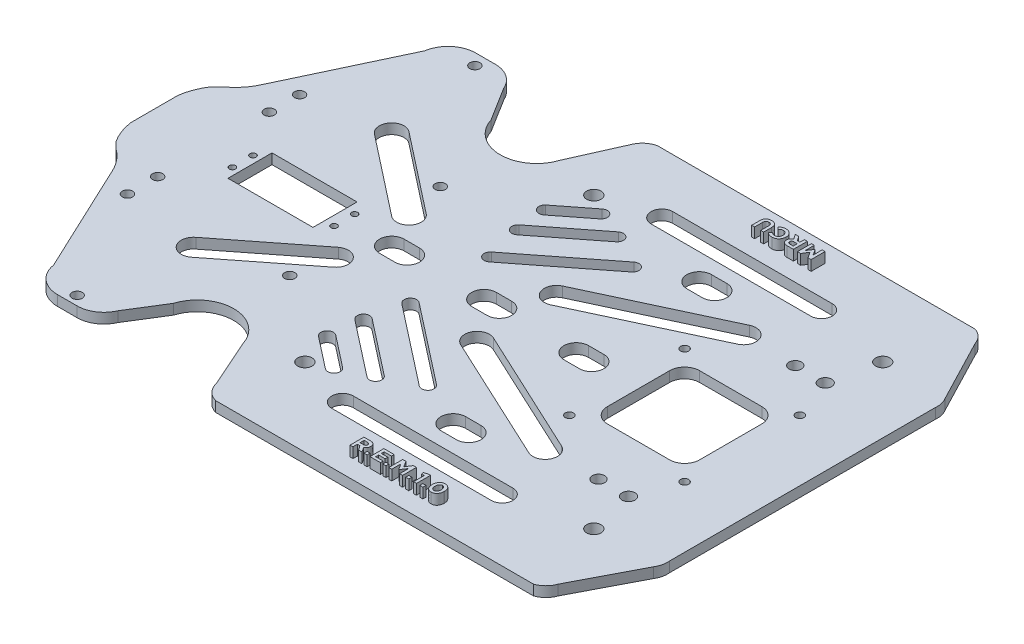
from build123d import *

# Parameters (mm, degrees)
SKETCH1_R           = 3.5
SKETCH1_R_2         = 2.5
SKETCH1_R_3         = 2
SKETCH1_R_4         = 1.5
SKETCH1_W           = 41.5
SKETCH1_H           = 21.5
BOSS_EXTRUDE4_DEPTH = 5
SKETCH2_W           = 1.506426403
SKETCH2_H           = 1.506425042
SKETCH2_W_2         = 1.506426404
BOSS_EXTRUDE5_DEPTH = 5


with BuildPart() as part:
    # Sketch1 → Boss-Extrude4 (new body)
    with BuildSketch(Plane(origin=(0, 0, 0), x_dir=(1, 0, 0), z_dir=(0, 1, 0))):
        with BuildLine():
            Line((-150.651835056, 26.425726461), (-153.297530537, 23.78003098))
            ThreePointArc((-153.297530537, 23.78003098), (-156.293626476, 18.057712499), (-157.845253288, 11.78762686))
            Line((-157.845253288, 11.78762686), (-157.845253288, -10.877537702))
            ThreePointArc((-157.845253288, -10.877537702), (-156.293626476, -17.147623341), (-153.297530537, -22.869941822))
            Line((-153.297530537, -22.869941822), (-150.651835056, -25.515637303))
            ThreePointArc((-150.651835056, -25.515637303), (-145.369806134, -30.45282715), (-141.639142644, -36.646196432))
            Line((-141.639142644, -36.646196432), (-116.473428846, -90.123338253))
            ThreePointArc((-116.473428846, -90.123338253), (-111.887885378, -98.354233742), (-103.050624746, -101.621904773))
            Line((-103.050624746, -101.621904773), (-93.49278288, -101.621904773))
            ThreePointArc((-93.49278288, -101.621904773), (-86.306020072, -99.470384794), (-81.483765332, -93.723693824))
            Line((-81.483765332, -93.723693824), (-71.092160533, -77.045715426))
            ThreePointArc((-71.092160533, -77.045715426), (-54.110025564, -64.559942515), (-37.127890596, -77.045715426))
            Line((-37.127890596, -77.045715426), (-26.687987231, -100.472694386))
            ThreePointArc((-26.687987231, -100.472694386), (-24.195796317, -105.133358769), (-19.658180017, -107.843127459))
            Line((-19.658180017, -107.843127459), (135.416108394, -107.843127459))
            ThreePointArc((135.416108394, -107.843127459), (139.142837684, -105.522737893), (141.474846039, -101.803268042))
            Line((141.474846039, -101.803268042), (157.346216018, -71.285102391))
            ThreePointArc((157.346216018, -71.285102391), (158.635275777, -68.269644616), (158.852211618, -64.997397759))
            Line((158.852211618, -64.997397759), (158.852211618, 64.840104165))
            ThreePointArc((158.852211618, 64.840104165), (158.635275777, 68.112351022), (157.346216018, 71.127808797))
            Line((157.346216018, 71.127808797), (141.474846039, 101.645974448))
            ThreePointArc((141.474846039, 101.645974448), (139.142837684, 105.365444299), (135.416108394, 107.685833865))
            Line((135.416108394, 107.685833865), (-19.658180017, 107.685833865))
            ThreePointArc((-19.658180017, 107.685833865), (-23.974543285, 105.428178597), (-26.687987231, 101.382783544))
            Line((-26.687987231, 101.382783544), (-37.127890596, 77.955804584))
            ThreePointArc((-37.127890596, 77.955804584), (-54.110025564, 65.470031673), (-71.092160533, 77.955804584))
            Line((-71.092160533, 77.955804584), (-81.483765332, 94.633782983))
            ThreePointArc((-81.483765332, 94.633782983), (-86.306020072, 100.380473953), (-93.49278288, 102.531993931))
            Line((-93.49278288, 102.531993931), (-103.050624746, 102.531993931))
            ThreePointArc((-103.050624746, 102.531993931), (-111.887885378, 99.2643229), (-116.473428846, 91.033427412))
            Line((-116.473428846, 91.033427412), (-141.639142644, 37.55628559))
            ThreePointArc((-141.639142644, 37.55628559), (-145.369806134, 31.362916309), (-150.651835056, 26.425726461))
        make_face()
        with Locations((126.785350398, 71.251763002)):
            Circle(SKETCH1_R, mode=Mode.SUBTRACT)
        with Locations((126.785350398, -69.748236998)):
            Circle(SKETCH1_R, mode=Mode.SUBTRACT)
        with Locations((-14.214649602, -69.748236998)):
            Circle(SKETCH1_R, mode=Mode.SUBTRACT)
        with Locations((-14.214649602, 71.251763002)):
            Circle(SKETCH1_R, mode=Mode.SUBTRACT)
        with Locations((-55.317055283, 37.432698705)):
            Circle(SKETCH1_R_2, mode=Mode.SUBTRACT)
        with Locations((-97.94691387, -97.121904773)):
            Circle(SKETCH1_R_2, mode=Mode.SUBTRACT)
        with Locations((-54.44373788, -36.910189328)):
            Circle(SKETCH1_R_2, mode=Mode.SUBTRACT)
        with Locations((-128.469873776, -27.328127459)):
            Circle(SKETCH1_R_2, mode=Mode.SUBTRACT)
        with Locations((129.066717469, 28.522168049)):
            Circle(SKETCH1_R_3, mode=Mode.SUBTRACT)
        with Locations((72.816717469, 28.522168049)):
            Circle(SKETCH1_R_3, mode=Mode.SUBTRACT)
        with Locations((72.816717469, -27.727831951)):
            Circle(SKETCH1_R_3, mode=Mode.SUBTRACT)
        with Locations((129.066717469, -27.727831951)):
            Circle(SKETCH1_R_3, mode=Mode.SUBTRACT)
        with Locations((-128.469873776, -42.068127459)):
            Circle(SKETCH1_R_2, mode=Mode.SUBTRACT)
        with Locations((-128.469873776, 41.911872541)):
            Circle(SKETCH1_R_2, mode=Mode.SUBTRACT)
        with Locations((-128.469873776, 27.171872541)):
            Circle(SKETCH1_R_2, mode=Mode.SUBTRACT)
        with Locations((-114.159440978, -5.164282294)):
            Circle(SKETCH1_R_4, mode=Mode.SUBTRACT)
        with Locations((-114.159440978, 4.885717706)):
            Circle(SKETCH1_R_4, mode=Mode.SUBTRACT)
        with Locations((-64.559440978, -5.164282294)):
            Circle(SKETCH1_R_4, mode=Mode.SUBTRACT)
        with Locations((-64.559440978, 4.885717706)):
            Circle(SKETCH1_R_4, mode=Mode.SUBTRACT)
        with Locations((-97.94691387, 96.965649855)):
            Circle(SKETCH1_R_2, mode=Mode.SUBTRACT)
        with BuildLine():
            Line((89.809281898, 83.569651302), (11.952031041, 83.569651302))
            ThreePointArc((11.952031041, 83.569651302), (6.702031041, 78.319651302), (11.952031041, 73.069651302))
            Line((11.952031041, 73.069651302), (89.809281898, 73.069651302))
            ThreePointArc((89.809281898, 73.069651302), (95.059281898, 78.319651302), (89.809281898, 83.569651302))
        make_face(mode=Mode.SUBTRACT)
        with BuildLine():
            Line((-6.436015983, 67.378434735), (-21.802225678, 55.373035966))
            ThreePointArc((-21.802225678, 55.373035966), (-22.672033007, 52.052777973), (-19.856796521, 50.089331651))
            ThreePointArc((-19.856796521, 50.089331651), (-18.936348022, 50.234025265), (-18.104688203, 50.654148611))
            Line((-18.104688203, 50.654148611), (-2.738478508, 62.65954738))
            ThreePointArc((-2.738478508, 62.65954738), (-2.129164012, 66.945049932), (-6.436015983, 67.378434735))
        make_face(mode=Mode.SUBTRACT)
        with BuildLine():
            Line((7.280972286, 61.712167773), (-19.905398714, 40.471846874))
            ThreePointArc((-19.905398714, 40.471846874), (-20.894970014, 37.13111015), (-18.058414288, 35.107814614))
            ThreePointArc((-18.058414288, 35.107814614), (-17.081709824, 35.271258887), (-16.211429862, 35.743782353))
            Line((-16.211429862, 35.743782353), (10.974941138, 56.984103252))
            ThreePointArc((10.974941138, 56.984103252), (11.491988973, 61.195119938), (7.280972286, 61.712167773))
        make_face(mode=Mode.SUBTRACT)
        with BuildLine():
            Line((23.811213387, 52.736443338), (-15.195318916, 22.26120031))
            ThreePointArc((-15.195318916, 22.26120031), (-16.184890217, 18.920463586), (-13.34833449, 16.897168049))
            ThreePointArc((-13.34833449, 16.897168049), (-12.371630027, 17.060612322), (-11.501350064, 17.533135788))
            Line((-11.501350064, 17.533135788), (27.505182239, 48.008378817))
            ThreePointArc((27.505182239, 48.008378817), (28.022230074, 52.219395504), (23.811213387, 52.736443338))
        make_face(mode=Mode.SUBTRACT)
        with BuildLine():
            Line((78.802429375, 54.275484778), (16.546859215, 25.24523565))
            ThreePointArc((16.546859215, 25.24523565), (13.644722064, 17.271679357), (21.618278356, 14.369542206))
            Line((21.618278356, 14.369542206), (83.873848516, 43.399791334))
            ThreePointArc((83.873848516, 43.399791334), (87.195914988, 50.13627574), (81.338138945, 54.837638056))
            ThreePointArc((81.338138945, 54.837638056), (80.039501262, 54.695414099), (78.802429375, 54.275484778))
        make_face(mode=Mode.SUBTRACT)
        with BuildLine():
            Line((48.066717469, 54.397168049), (55.566717469, 54.397168049))
            ThreePointArc((55.566717469, 54.397168049), (61.566717469, 60.397168049), (55.566717469, 66.397168049))
            Line((55.566717469, 66.397168049), (48.066717469, 66.397168049))
            ThreePointArc((48.066717469, 66.397168049), (42.066717469, 60.397168049), (48.066717469, 54.397168049))
        make_face(mode=Mode.SUBTRACT)
        with BuildLine():
            Line((-86.060715194, -53.061693245), (-47.099872951, -22.528059794))
            ThreePointArc((-47.099872951, -22.528059794), (-46.177380086, -14.181028105), (-54.50374552, -13.08760698))
            Line((-54.50374552, -13.08760698), (-93.464587763, -43.621240431))
            ThreePointArc((-93.464587763, -43.621240431), (-95.550522316, -50.317795247), (-89.859440978, -54.417376028))
            ThreePointArc((-89.859440978, -54.417376028), (-87.84274855, -54.068300877), (-86.060715194, -53.061693245))
        make_face(mode=Mode.SUBTRACT)
        with BuildLine():
            Line((48.066717469, -5.602831951), (55.566717469, -5.602831951))
            ThreePointArc((55.566717469, -5.602831951), (61.566717469, 0.397168049), (55.566717469, 6.397168049))
            Line((55.566717469, 6.397168049), (48.066717469, 6.397168049))
            ThreePointArc((48.066717469, 6.397168049), (42.066717469, 0.397168049), (48.066717469, -5.602831951))
        make_face(mode=Mode.SUBTRACT)
        with BuildLine():
            Line((3.066717469, -5.602831951), (10.566717469, -5.602831951))
            ThreePointArc((10.566717469, -5.602831951), (16.566717469, 0.397168049), (10.566717469, 6.397168049))
            Line((10.566717469, 6.397168049), (3.066717469, 6.397168049))
            ThreePointArc((3.066717469, 6.397168049), (-2.933282531, 0.397168049), (3.066717469, -5.602831951))
        make_face(mode=Mode.SUBTRACT)
        with BuildLine():
            Line((-41.933282531, -5.602831951), (-34.433282531, -5.602831951))
            ThreePointArc((-34.433282531, -5.602831951), (-28.433282531, 0.397168049), (-34.433282531, 6.397168049))
            Line((-34.433282531, 6.397168049), (-41.933282531, 6.397168049))
            ThreePointArc((-41.933282531, 6.397168049), (-47.933282531, 0.397168049), (-41.933282531, -5.602831951))
        make_face(mode=Mode.SUBTRACT)
        with BuildLine():
            Line((-19.905398714, -39.677510776), (7.280972286, -60.917831675))
            ThreePointArc((7.280972286, -60.917831675), (8.151252249, -61.390355141), (9.127956712, -61.553799414))
            ThreePointArc((9.127956712, -61.553799414), (11.964512439, -59.530503878), (10.974941138, -56.189767154))
            Line((10.974941138, -56.189767154), (-16.211429862, -34.949446255))
            ThreePointArc((-16.211429862, -34.949446255), (-20.422446548, -35.46649409), (-19.905398714, -39.677510776))
        make_face(mode=Mode.SUBTRACT)
        with BuildLine():
            Line((-15.195318916, -21.466864212), (23.811213387, -51.94210724))
            ThreePointArc((23.811213387, -51.94210724), (24.68149335, -52.414630706), (25.658197813, -52.57807498))
            ThreePointArc((25.658197813, -52.57807498), (28.49475354, -50.554779443), (27.505182239, -47.214042719))
            Line((27.505182239, -47.214042719), (-11.501350064, -16.73879969))
            ThreePointArc((-11.501350064, -16.73879969), (-15.712366751, -17.255847525), (-15.195318916, -21.466864212))
        make_face(mode=Mode.SUBTRACT)
        with BuildLine():
            Line((48.066717469, -65.602831951), (55.566717469, -65.602831951))
            ThreePointArc((55.566717469, -65.602831951), (61.566717469, -59.602831951), (55.566717469, -53.602831951))
            Line((55.566717469, -53.602831951), (48.066717469, -53.602831951))
            ThreePointArc((48.066717469, -53.602831951), (42.066717469, -59.602831951), (48.066717469, -65.602831951))
        make_face(mode=Mode.SUBTRACT)
        with BuildLine():
            Line((11.952031041, -82.775315204), (89.809281898, -82.775315204))
            ThreePointArc((89.809281898, -82.775315204), (95.059281898, -77.525315204), (89.809281898, -72.275315204))
            Line((89.809281898, -72.275315204), (11.952031041, -72.275315204))
            ThreePointArc((11.952031041, -72.275315204), (6.702031041, -77.525315204), (11.952031041, -82.775315204))
        make_face(mode=Mode.SUBTRACT)
        with BuildLine():
            Line((116.134000275, 22.897168049), (85.749434663, 22.897168049))
            ThreePointArc((85.749434663, 22.897168049), (80.58209828, 20.756787238), (78.441717469, 15.589450855))
            Line((78.441717469, 15.589450855), (78.441717469, -14.795114757))
            ThreePointArc((78.441717469, -14.795114757), (80.58209828, -19.96245114), (85.749434663, -22.102831951))
            Line((85.749434663, -22.102831951), (116.134000275, -22.102831951))
            ThreePointArc((116.134000275, -22.102831951), (121.301336658, -19.96245114), (123.441717469, -14.795114757))
            Line((123.441717469, -14.795114757), (123.441717469, 15.589450855))
            ThreePointArc((123.441717469, 15.589450855), (121.301336658, 20.756787238), (116.134000275, 22.897168049))
        make_face(mode=Mode.SUBTRACT)
        with BuildLine():
            Line((16.546859215, -24.450899552), (78.802429375, -53.48114868))
            ThreePointArc((78.802429375, -53.48114868), (86.775985667, -50.579011528), (83.873848516, -42.605455236))
            Line((83.873848516, -42.605455236), (21.618278356, -13.575206108))
            ThreePointArc((21.618278356, -13.575206108), (20.381206469, -13.155276787), (19.082568786, -13.01305283))
            ThreePointArc((19.082568786, -13.01305283), (13.224792743, -17.714415146), (16.546859215, -24.450899552))
        make_face(mode=Mode.SUBTRACT)
        with BuildLine():
            Line((-86.060715194, 52.905438327), (-47.099872951, 22.371804877))
            ThreePointArc((-47.099872951, 22.371804877), (-46.177380086, 14.024773187), (-54.50374552, 12.931352063))
            Line((-54.50374552, 12.931352063), (-93.464587763, 43.464985514))
            ThreePointArc((-93.464587763, 43.464985514), (-95.550522316, 50.16154033), (-89.859440978, 54.26112111))
            ThreePointArc((-89.859440978, 54.26112111), (-87.84274855, 53.912045959), (-86.060715194, 52.905438327))
        make_face(mode=Mode.SUBTRACT)
        with BuildLine():
            Line((-18.104688203, -50.810403528), (-2.738478508, -62.815802297))
            ThreePointArc((-2.738478508, -62.815802297), (-2.129164012, -67.101304849), (-6.436015983, -67.534689652))
            Line((-6.436015983, -67.534689652), (-21.802225678, -55.529290883))
            ThreePointArc((-21.802225678, -55.529290883), (-22.672033007, -52.20903289), (-19.856796521, -50.245586569))
            ThreePointArc((-19.856796521, -50.245586569), (-18.936348022, -50.390280182), (-18.104688203, -50.810403528))
        make_face(mode=Mode.SUBTRACT)
        with Locations((-89.859440978, -0.139282294)):
            Rectangle(SKETCH1_W, SKETCH1_H, mode=Mode.SUBTRACT)
        with BuildLine():
            ThreePointArc((121.566717469, 45.247168049), (124.716717469, 48.397168049), (121.566717469, 51.547168049))
            ThreePointArc((121.566717469, 51.547168049), (118.416717469, 48.397168049), (121.566717469, 45.247168049))
        make_face(mode=Mode.SUBTRACT)
        with BuildLine():
            ThreePointArc((106.941717469, 45.397168049), (109.941717469, 48.397168049), (106.941717469, 51.397168049))
            ThreePointArc((106.941717469, 51.397168049), (103.941717469, 48.397168049), (106.941717469, 45.397168049))
        make_face(mode=Mode.SUBTRACT)
        with BuildLine():
            ThreePointArc((106.941717469, -50.602831951), (109.941717469, -47.602831951), (106.941717469, -44.602831951))
            ThreePointArc((106.941717469, -44.602831951), (103.941717469, -47.602831951), (106.941717469, -50.602831951))
        make_face(mode=Mode.SUBTRACT)
        with BuildLine():
            ThreePointArc((121.566717469, -44.452831951), (118.416717469, -47.602831951), (121.566717469, -50.752831951))
            ThreePointArc((121.566717469, -50.752831951), (124.716717469, -47.602831951), (121.566717469, -44.452831951))
        make_face(mode=Mode.SUBTRACT)
    extrude(amount=BOSS_EXTRUDE4_DEPTH)

    # Sketch2 → Boss-Extrude5 (add)
    with BuildSketch(Plane(origin=(0, 5, 0), x_dir=(1, 0, 0), z_dir=(0, 1, 0))):
        with BuildLine():
            Line((36.93226285, -98.837549469), (38.349419621, -98.837549469))
            Line((38.349419621, -98.837549469), (38.349419621, -96.686741963))
            Line((38.349419621, -96.686741963), (39.576502472, -96.686741963))
            Line((39.576502472, -96.686741963), (41.097679559, -98.837549469))
            Line((41.097679559, -98.837549469), (42.747557695, -98.837549469))
            Line((42.747557695, -98.837549469), (41.182439124, -96.436068869))
            add(Edge.make_bspline(
                [(41.182439124, -96.436068869), (41.232495375, -96.415759477), (41.331901229, -96.375427403), (41.474000985, -96.301982888), (41.609887155, -96.221621628), (41.737392019, -96.130727901), (41.855371764, -96.02940522), (41.968290704, -95.922342324), (42.071493, -95.804062865), (42.16763074, -95.677708417), (42.2552616, -95.54173216), (42.329839018, -95.395088162), (42.394511693, -95.239423439), (42.447376928, -95.074204287), (42.489191442, -94.898889314), (42.519806985, -94.71388545), (42.537490295, -94.518990612), (42.541597203, -94.386188466), (42.54369749, -94.318272983)],
                knots=[0, 0, 0, 0, 0.000161982, 0.000321677, 0.000479319, 0.000635304, 0.000790683, 0.00094556, 0.001101707, 0.001261, 0.001421576, 0.001586267, 0.001753863, 0.001926777, 0.002106083, 0.002294118, 0.002488846, 0.002692664, 0.002692664, 0.002692664, 0.002692664], degree=3))
            Line((42.54369749, -94.318272983), (42.545090966, -94.298053281))
            add(Edge.make_bspline(
                [(42.545090966, -94.298053281), (42.542503237, -94.217781145), (42.537456432, -94.061227784), (42.511176344, -93.833230559), (42.467552585, -93.618787705), (42.409769876, -93.41649459), (42.332984582, -93.2275577), (42.238330846, -93.052617737), (42.130622181, -92.88825266), (42.043339274, -92.791742001), (41.99971067, -92.74350088)],
                knots=[0, 0, 0, 0, 0.000240874, 0.000469772, 0.000687518, 0.000896744, 0.001100075, 0.001297896, 0.001492874, 0.001687738, 0.001687738, 0.001687738, 0.001687738], degree=3))
            add(Edge.make_bspline(
                [(41.99971067, -92.74350088), (41.945832837, -92.689741667), (41.836879962, -92.581028666), (41.643703577, -92.446853047), (41.430781132, -92.330129995), (41.194186774, -92.235350066), (40.935109055, -92.161889992), (40.653448337, -92.110125592), (40.349982268, -92.075790004), (40.140025549, -92.070916295), (40.03159425, -92.068399287)],
                knots=[0, 0, 0, 0, 0.00022794, 0.000460945, 0.000702509, 0.00095531, 0.001223736, 0.001509064, 0.00181359, 0.00213883, 0.00213883, 0.00213883, 0.00213883], degree=3))
            Line((40.03159425, -92.068399287), (36.93226285, -92.067733198))
            Line((36.93226285, -92.067733198), (36.93226285, -98.837549469))
        make_face()
        with BuildLine():
            Line((38.349419621, -95.375528859), (38.349419621, -93.388586212))
            Line((38.349419621, -93.388586212), (39.90102025, -93.388586212))
            add(Edge.make_bspline(
                [(39.90102025, -93.388586212), (39.947351753, -93.389797843), (40.037998232, -93.39216837), (40.170235041, -93.402765258), (40.295218415, -93.422259631), (40.411755282, -93.449974111), (40.520697691, -93.484830285), (40.620962277, -93.528109733), (40.714160049, -93.578577766), (40.799044614, -93.636738217), (40.875368997, -93.703143775), (40.942543438, -93.776644392), (40.998655142, -93.858650729), (41.045171969, -93.947509497), (41.081974, -94.044312621), (41.105645619, -94.149605066), (41.123784414, -94.261402748), (41.125607486, -94.33865021), (41.126542081, -94.378251017)],
                knots=[0, 0, 0, 0, 0.00013903, 0.000272008, 0.000397675, 0.000518117, 0.000631039, 0.00074038, 0.000845244, 0.000948547, 0.001048402, 0.00114814, 0.001246414, 0.001345615, 0.001448464, 0.001556048, 0.001668883, 0.001787576, 0.001787576, 0.001787576, 0.001787576], degree=3))
            Line((41.126542081, -94.378251017), (41.127934195, -94.396904251))
            add(Edge.make_bspline(
                [(41.127934195, -94.396904251), (41.126247912, -94.433054739), (41.12293983, -94.503973327), (41.10730277, -94.606933424), (41.084152772, -94.705105517), (41.048762926, -94.796354176), (41.00578855, -94.883331503), (40.949910347, -94.962401867), (40.888028968, -95.03867147), (40.814141188, -95.106401341), (40.734062586, -95.1705669), (40.642155284, -95.222184612), (40.544324755, -95.269341796), (40.437343757, -95.306137219), (40.323012178, -95.337788737), (40.199452692, -95.357294643), (40.068208854, -95.37213903), (39.977707149, -95.374398326), (39.931165914, -95.375560188)],
                knots=[0, 0, 0, 0, 0.000108501, 0.000212853, 0.000311975, 0.000410418, 0.00050586, 0.000602194, 0.000700241, 0.000799901, 0.000902296, 0.001007317, 0.001115261, 0.00122776, 0.001346182, 0.001470698, 0.001602553, 0.001742148, 0.001742148, 0.001742148, 0.001742148], degree=3))
            Line((39.931165914, -95.375560188), (38.349419621, -95.375528859))
        make_face(mode=Mode.SUBTRACT)
        with Locations((44.469968088, -98.084335586)):
            Rectangle(SKETCH2_W, SKETCH2_H)
        Polygon((46.662652745, -98.834032407), (51.74349319, -98.834032407), (51.74349319, -97.51317803), (48.079809517, -97.51317803), (48.079809517, -96.066675175), (51.261429548, -96.066675175), (51.261429548, -94.745820798), (48.079809517, -94.745820798), (48.079809517, -93.388587575), (51.695286826, -93.388587575), (51.695286826, -92.067733198), (46.662652745, -92.067733198), align=None)
        with Locations((53.664740192, -98.084335586)):
            Rectangle(SKETCH2_W_2, SKETCH2_H)
        Polygon((55.857424849, -98.837549469), (57.27458162, -98.837549469), (57.27458162, -94.44433283), (59.170301316, -97.308632665), (59.209187874, -97.308632665), (61.124331779, -94.415302764), (61.124331779, -98.837549469), (62.54148855, -98.837549469), (62.54148855, -92.064216135), (60.997969536, -92.064216135), (59.209187874, -94.928167261), (57.420406212, -92.064216135), (55.857424849, -92.064216135), align=None)
        with Locations((64.823444201, -98.084335586)):
            Rectangle(SKETCH2_W, SKETCH2_H)
        Polygon((67.908825178, -98.837549469), (69.325981949, -98.837549469), (69.325981949, -91.974946503), (68.347048135, -91.974946503), (66.424069163, -92.559184752), (66.732589893, -93.785655999), (67.908825178, -93.493639036), align=None)
        with Locations((71.69720587, -98.084335586)):
            Rectangle(SKETCH2_W_2, SKETCH2_H)
        with BuildLine():
            add(Edge.make_bspline(
                [(76.552539558, -98.923302039), (76.664395208, -98.918547638), (76.883724755, -98.909225082), (77.202145933, -98.854101454), (77.503473369, -98.774553925), (77.784730456, -98.661893535), (78.047930418, -98.522192428), (78.290928278, -98.351535691), (78.515412117, -98.152490064), (78.718016633, -97.924888376), (78.898947463, -97.674585124), (79.058269442, -97.40688599), (79.192969897, -97.121424241), (79.302681056, -96.819599732), (79.389455575, -96.501419513), (79.451715618, -96.166483495), (79.491400556, -95.814935788), (79.497975912, -95.574662862), (79.501325167, -95.452276278)],
                knots=[0, 0, 0, 0, 0.000335555, 0.000657964, 0.000967229, 0.001268981, 0.001564769, 0.001859242, 0.002157633, 0.00246286, 0.002771435, 0.003082893, 0.003396111, 0.003716915, 0.004045141, 0.004384365, 0.004738027, 0.00510519, 0.00510519, 0.00510519, 0.00510519], degree=3))
            Line((79.501325167, -95.452276278), (79.502718643, -95.431628862))
            add(Edge.make_bspline(
                [(79.502718643, -95.431628862), (79.498770665, -95.309624848), (79.491023842, -95.070225471), (79.451884434, -94.719420375), (79.388742461, -94.385338133), (79.305510745, -94.066963449), (79.1917957, -93.767448324), (79.05896229, -93.48318106), (78.900097524, -93.216735411), (78.71925676, -92.969000607), (78.518719866, -92.742224339), (78.294687849, -92.545950631), (78.053350496, -92.377511301), (77.793885924, -92.236247912), (77.513959944, -92.128166294), (77.216818781, -92.047084061), (76.900792162, -91.994464121), (76.683491224, -91.98432437), (76.572165365, -91.979129655)],
                knots=[0, 0, 0, 0, 0.000366105, 0.000718381, 0.001057605, 0.001385466, 0.001704137, 0.002017355, 0.002325703, 0.00263315, 0.002936408, 0.003231906, 0.003524437, 0.003817767, 0.004115901, 0.004422473, 0.004740527, 0.00507464, 0.00507464, 0.00507464, 0.00507464], degree=3))
            add(Edge.make_bspline(
                [(76.572165365, -91.979129655), (76.45988236, -91.984159811), (76.240602931, -91.993983288), (75.92257871, -92.048866643), (75.623077498, -92.129080696), (75.34179369, -92.239534211), (75.080083095, -92.381315208), (74.836621741, -92.551508977), (74.612106432, -92.750637205), (74.409744741, -92.978720254), (74.226983706, -93.228057583), (74.068209768, -93.496662579), (73.931853286, -93.78164003), (73.820336852, -94.08327588), (73.734287678, -94.40236784), (73.670058895, -94.736993057), (73.630591203, -95.089161883), (73.624038504, -95.329429251), (73.620688155, -95.452276278)],
                knots=[0, 0, 0, 0, 0.000336896, 0.00065793, 0.000965848, 0.00126579, 0.001562238, 0.001856711, 0.002155102, 0.00246033, 0.002769726, 0.003081184, 0.003395001, 0.003716287, 0.004044512, 0.004385367, 0.004737643, 0.0051062, 0.0051062, 0.0051062, 0.0051062], degree=3))
            Line((73.620688155, -95.452276278), (73.622081631, -95.470221196))
            add(Edge.make_bspline(
                [(73.622081631, -95.470221196), (73.624982102, -95.592659544), (73.63066324, -95.832478875), (73.668652506, -96.183771774), (73.731257188, -96.51814016), (73.81761749, -96.835365071), (73.926933066, -97.135964285), (74.05874552, -97.420295519), (74.217884707, -97.685988184), (74.397111822, -97.934112307), (74.596358502, -98.161324786), (74.82039871, -98.357166838), (75.061688919, -98.525624656), (75.321485458, -98.667246201), (75.602523844, -98.774928493), (75.901453672, -98.856264198), (76.219850811, -98.908654886), (76.438991861, -98.918820775), (76.551242795, -98.924028063)],
                knots=[0, 0, 0, 0, 0.000367295, 0.000719419, 0.001058643, 0.001386869, 0.001704574, 0.002017198, 0.002325546, 0.002632172, 0.002934502, 0.00323, 0.00352253, 0.003815861, 0.004115294, 0.004423212, 0.004744019, 0.005080915, 0.005080915, 0.005080915, 0.005080915], degree=3))
            Line((76.551242795, -98.924028063), (76.552539558, -98.923302039))
        make_face()
        with BuildLine():
            add(Edge.make_bspline(
                [(76.572451416, -97.602447662), (76.515040198, -97.599308317), (76.402775174, -97.593169471), (76.238900644, -97.562251991), (76.085208084, -97.511395499), (75.93925005, -97.444336986), (75.804088664, -97.356875341), (75.677194976, -97.253021349), (75.561022806, -97.13004738), (75.454432819, -96.990989379), (75.358083707, -96.837404551), (75.274995706, -96.671245545), (75.203402789, -96.494545811), (75.144966075, -96.306949303), (75.099225675, -96.108740314), (75.065832778, -95.899510737), (75.044743511, -95.679591376), (75.041097453, -95.529039605), (75.039238402, -95.452276278)],
                knots=[0, 0, 0, 0, 0.000172363, 0.000337049, 0.000498489, 0.000656992, 0.000817568, 0.000980089, 0.001147806, 0.001323849, 0.001504969, 0.001690859, 0.00188046, 0.002076334, 0.002279679, 0.002490189, 0.002711564, 0.002941865, 0.002941865, 0.002941865, 0.002941865], degree=3))
            Line((75.039238402, -95.452276278), (75.039238402, -95.431628862))
            add(Edge.make_bspline(
                [(75.039238402, -95.431628862), (75.041027641, -95.355227246), (75.044534335, -95.205489214), (75.066654777, -94.986183089), (75.096890202, -94.776960401), (75.144179069, -94.57976746), (75.200149796, -94.392963583), (75.272187957, -94.218588375), (75.354257071, -94.054373062), (75.448365481, -93.902511493), (75.554540628, -93.766071676), (75.668729155, -93.644444189), (75.794192511, -93.54257208), (75.92692085, -93.455586798), (76.070966725, -93.390652517), (76.222758288, -93.340932533), (76.384101671, -93.310224308), (76.49485926, -93.303476407), (76.551242795, -93.300041242)],
                knots=[0, 0, 0, 0, 0.000229181, 0.000449168, 0.000660839, 0.000862826, 0.001056954, 0.001245262, 0.001428034, 0.001607231, 0.001780214, 0.001945959, 0.002106517, 0.002263992, 0.002420643, 0.002578998, 0.002742313, 0.002911664, 0.002911664, 0.002911664, 0.002911664], degree=3))
            add(Edge.make_bspline(
                [(76.551242795, -93.300041242), (76.60811911, -93.303311383), (76.719487341, -93.309714571), (76.881591227, -93.342647792), (77.03438161, -93.393385426), (77.179694585, -93.459901958), (77.31446145, -93.54795336), (77.440153819, -93.653459566), (77.558728485, -93.775457), (77.664847519, -93.916438241), (77.760086489, -94.07119031), (77.846484343, -94.235906457), (77.916639286, -94.413164438), (77.977517024, -94.60007939), (78.022765186, -94.798639986), (78.055651452, -95.007454675), (78.079164006, -95.226260315), (78.082479558, -95.375961614), (78.084169758, -95.452276278)],
                knots=[0, 0, 0, 0, 0.000170741, 0.000334324, 0.000494439, 0.000652942, 0.000812345, 0.000975755, 0.001144438, 0.001321588, 0.001503891, 0.001689173, 0.001878774, 0.00207507, 0.002278415, 0.002488925, 0.002709048, 0.002937955, 0.002937955, 0.002937955, 0.002937955], degree=3))
            Line((78.084169758, -95.452276278), (78.085561872, -95.470221196))
            add(Edge.make_bspline(
                [(78.085561872, -95.470221196), (78.082966772, -95.546563732), (78.077897525, -95.695690636), (78.059359326, -95.91446652), (78.025445268, -96.121648222), (77.981071817, -96.318478001), (77.924308178, -96.504337276), (77.85363302, -96.679165827), (77.774091048, -96.844806622), (77.678439858, -96.995981795), (77.575166192, -97.134781098), (77.459587227, -97.255610748), (77.335217009, -97.359945287), (77.200425338, -97.44533183), (77.05670453, -97.513249137), (76.903327316, -97.562039724), (76.740715048, -97.592980213), (76.629020738, -97.5996973), (76.572451416, -97.602447662)],
                knots=[0, 0, 0, 0, 0.000229149, 0.000447619, 0.000658128, 0.000858442, 0.00105257, 0.001240356, 0.001423754, 0.001602952, 0.001776193, 0.001941938, 0.002103384, 0.002262034, 0.002419274, 0.002578957, 0.002743642, 0.002914383, 0.002914383, 0.002914383, 0.002914383], degree=3))
        make_face(mode=Mode.SUBTRACT)
        with BuildLine():
            add(Edge.make_bspline(
                [(44.939572396, 98.923302039), (44.827872684, 98.920922961), (44.61050311, 98.916293234), (44.29337148, 98.883503245), (43.996512357, 98.824273641), (43.717234622, 98.746029408), (43.458474532, 98.640134651), (43.216947004, 98.514122475), (42.996298385, 98.361407832), (42.794270823, 98.187257967), (42.61437201, 97.987189486), (42.45733549, 97.763152015), (42.326096087, 97.513233899), (42.217046322, 97.239844361), (42.132525515, 96.941503177), (42.072357853, 96.618853159), (42.031984947, 96.272049922), (42.02687363, 96.032184128), (42.024235656, 95.908388304)],
                knots=[0, 0, 0, 0, 0.000335095, 0.000652101, 0.000954922, 0.001242317, 0.001520761, 0.001792181, 0.002057981, 0.002323957, 0.002590615, 0.002863034, 0.003142576, 0.003435522, 0.003744566, 0.004071197, 0.004419314, 0.004790603, 0.004790603, 0.004790603, 0.004790603], degree=3))
            Line((42.024235656, 95.908388304), (42.024237018, 92.064216135))
            Line((42.024237018, 92.064216135), (43.441393789, 92.064216135))
            Line((43.441393789, 92.064216135), (43.441393789, 95.967152666))
            add(Edge.make_bspline(
                [(43.441393789, 95.967152666), (43.442758569, 96.032699545), (43.445408557, 96.159971682), (43.46507664, 96.344608982), (43.497053061, 96.516651725), (43.54010881, 96.676318589), (43.594154327, 96.823895581), (43.661253975, 96.958825264), (43.741228983, 97.080716259), (43.83228724, 97.190456458), (43.934728113, 97.286950606), (44.046980562, 97.371250183), (44.169200086, 97.442646338), (44.300516023, 97.501416335), (44.441914369, 97.546240012), (44.592411055, 97.577653043), (44.752931487, 97.597782596), (44.863133435, 97.600382127), (44.919919346, 97.601721638)],
                knots=[0, 0, 0, 0, 0.000196615, 0.000381766, 0.000556305, 0.00072109, 0.000877325, 0.001027035, 0.001172111, 0.001313734, 0.001453844, 0.001593327, 0.001733992, 0.001877599, 0.002024051, 0.002178071, 0.002338277, 0.00250859, 0.00250859, 0.00250859, 0.00250859], degree=3))
            add(Edge.make_bspline(
                [(44.919919346, 97.601721638), (44.976228612, 97.600298266), (45.086404093, 97.597513276), (45.246713967, 97.578296497), (45.397645842, 97.544632874), (45.538473998, 97.497564285), (45.669563055, 97.436650528), (45.791982489, 97.364394386), (45.903696249, 97.27697483), (46.006696641, 97.177744874), (46.09718032, 97.063773024), (46.177338753, 96.93783889), (46.243954614, 96.798392142), (46.300020919, 96.647270598), (46.343237733, 96.482812972), (46.372810663, 96.305809211), (46.392901725, 96.116194646), (46.396558199, 95.98562309), (46.398447627, 95.91815217)],
                knots=[0, 0, 0, 0, 0.000168919, 0.00033051, 0.000483466, 0.000632113, 0.000775028, 0.000916402, 0.001057578, 0.001199619, 0.00134448, 0.001493075, 0.001646539, 0.001807181, 0.001976009, 0.002155791, 0.002345104, 0.002547529, 0.002547529, 0.002547529, 0.002547529], degree=3))
            Line((46.398447627, 95.91815217), (46.398447627, 92.064216135))
            Line((46.398447627, 92.064216135), (47.815604399, 92.064216135))
            Line((47.815604399, 92.064216135), (47.815604399, 95.957418767))
            add(Edge.make_bspline(
                [(47.815604399, 95.957418767), (47.812836133, 96.077879372), (47.807476293, 96.311111863), (47.768841807, 96.649066736), (47.709571747, 96.964035772), (47.628363583, 97.256488332), (47.522229645, 97.52519002), (47.391486373, 97.769501062), (47.23938592, 97.992047002), (47.062263663, 98.189402291), (46.864553288, 98.363442653), (46.646664344, 98.513001482), (46.410275122, 98.641008129), (46.154240489, 98.746008187), (45.877442128, 98.824645284), (45.582015906, 98.881267951), (45.267181704, 98.917067796), (45.050668513, 98.920744517), (44.939572396, 98.923302039)],
                knots=[0, 0, 0, 0, 0.000361321, 0.00069958, 0.001019099, 0.001322013, 0.001608743, 0.001883936, 0.002151676, 0.002415434, 0.00267734, 0.002940051, 0.003206553, 0.003482414, 0.003768468, 0.004068283, 0.004384053, 0.004717606, 0.004717606, 0.004717606, 0.004717606], degree=3))
        make_face()
        with BuildLine():
            add(Edge.make_bspline(
                [(51.988124702, 98.923302039), (51.909336553, 98.921896474), (51.755055942, 98.919144138), (51.52865284, 98.903645068), (51.312126831, 98.878953812), (51.105581414, 98.843673936), (50.908751843, 98.801338139), (50.722087932, 98.747742624), (50.544760805, 98.685554681), (50.321960743, 98.588046145), (50.057269738, 98.446827098), (49.7587576, 98.246756597), (49.476079138, 98.019924283), (49.305960673, 97.846673224), (49.220204904, 97.759338332)],
                knots=[0, 0, 0, 0, 0.000236371, 0.000462855, 0.000680508, 0.000889869, 0.001091238, 0.001284175, 0.001472111, 0.001654531, 0.002013333, 0.002370403, 0.002731367, 0.003098292, 0.003098292, 0.003098292, 0.003098292], degree=3))
            Line((49.220204904, 97.759338332), (50.165924139, 96.800470297))
            add(Edge.make_bspline(
                [(50.165924139, 96.800470297), (50.230349886, 96.859536033), (50.356494593, 96.975185912), (50.553326188, 97.132822543), (50.755511492, 97.267477407), (50.959903125, 97.388277828), (51.178521634, 97.483524185), (51.414545614, 97.552049817), (51.670510838, 97.592233854), (51.847471341, 97.598493192), (51.938744168, 97.601721638)],
                knots=[0, 0, 0, 0, 0.000262183, 0.000513351, 0.000755527, 0.000990473, 0.001224727, 0.001468824, 0.001725887, 0.001999705, 0.001999705, 0.001999705, 0.001999705], degree=3))
            add(Edge.make_bspline(
                [(51.938744168, 97.601721638), (52.010469218, 97.597957456), (52.150930825, 97.59058593), (52.356240526, 97.55676273), (52.54988647, 97.503551486), (52.733763234, 97.433870407), (52.905201153, 97.34371898), (53.067499891, 97.237546506), (53.216985936, 97.110816787), (53.354559159, 96.96753433), (53.477687616, 96.810244597), (53.587259308, 96.643431888), (53.681681864, 96.467549173), (53.756240012, 96.280820768), (53.816746795, 96.085902553), (53.861156114, 95.882033155), (53.889804693, 95.668799617), (53.89463569, 95.523503905), (53.897096721, 95.449486602)],
                knots=[0, 0, 0, 0, 0.000215352, 0.000421732, 0.000622729, 0.000817007, 0.001010408, 0.001202678, 0.001397701, 0.001596972, 0.001797606, 0.001996071, 0.002195122, 0.002395344, 0.002598291, 0.002806772, 0.003020615, 0.003242674, 0.003242674, 0.003242674, 0.003242674], degree=3))
            Line((53.897096721, 95.449486602), (53.897096721, 95.43124065))
            add(Edge.make_bspline(
                [(53.897096721, 95.43124065), (53.894044146, 95.357266953), (53.888051442, 95.212044514), (53.859904511, 94.999263104), (53.815635412, 94.796085811), (53.753449237, 94.602704292), (53.677194837, 94.417778182), (53.58323222, 94.242572489), (53.472411059, 94.077645569), (53.347013544, 93.922978681), (53.209242743, 93.781269095), (53.058151231, 93.657572685), (52.897964019, 93.550769307), (52.725663601, 93.46405779), (52.544005784, 93.394088165), (52.351552077, 93.342007961), (52.148481949, 93.310253408), (52.009521319, 93.302563251), (51.938744168, 93.298646404)],
                knots=[0, 0, 0, 0, 0.000222021, 0.000435864, 0.000642982, 0.000845017, 0.001044479, 0.0012423, 0.001440372, 0.001639698, 0.00183894, 0.002032179, 0.002224449, 0.002415333, 0.002609612, 0.002807551, 0.003012331, 0.003224901, 0.003224901, 0.003224901, 0.003224901], degree=3))
            add(Edge.make_bspline(
                [(51.938744168, 93.298646404), (51.8567533, 93.30144476), (51.695087814, 93.306962418), (51.458315173, 93.347128808), (51.231664674, 93.41118059), (51.015553745, 93.502236376), (50.80667773, 93.614477717), (50.604614671, 93.748975057), (50.403382111, 93.898745555), (50.277501823, 94.013093463), (50.21332956, 94.071386657)],
                knots=[0, 0, 0, 0, 0.000245887, 0.000484829, 0.000718384, 0.000951, 0.001186893, 0.001428687, 0.001678643, 0.001938581, 0.001938581, 0.001938581, 0.001938581], degree=3))
            Line((50.21332956, 94.071386657), (49.269285766, 92.983045237))
            add(Edge.make_bspline(
                [(49.269285766, 92.983045237), (49.347732998, 92.909413924), (49.505030039, 92.761773435), (49.768854876, 92.569459849), (50.052878558, 92.399106739), (50.305643247, 92.275758532), (50.520463448, 92.189594596), (50.693178799, 92.134849399), (50.875377411, 92.086240729), (51.067875983, 92.050716212), (51.268889841, 92.016924986), (51.480420123, 91.995706823), (51.701426014, 91.98136542), (51.852240138, 91.978959198), (51.928980302, 91.977734817)],
                knots=[0, 0, 0, 0, 0.000322515, 0.000646685, 0.000977038, 0.001315153, 0.001489212, 0.001670948, 0.001858376, 0.002054513, 0.002257916, 0.002469716, 0.002691933, 0.002922149, 0.002922149, 0.002922149, 0.002922149], degree=3))
            add(Edge.make_bspline(
                [(51.928980302, 91.977734817), (52.057005273, 91.983569482), (52.307518629, 91.994986485), (52.6732464, 92.046748649), (53.019330905, 92.128905791), (53.345262866, 92.24082558), (53.652111589, 92.379865012), (53.936293091, 92.55252081), (54.203658418, 92.750266204), (54.445961523, 92.979875868), (54.666393579, 93.22951433), (54.857755449, 93.498973288), (55.023065237, 93.783518695), (55.155967168, 94.085876418), (55.263269276, 94.403607807), (55.340640995, 94.737572811), (55.390784626, 95.088147101), (55.399221773, 95.327500294), (55.403521763, 95.449486602)],
                knots=[0, 0, 0, 0, 0.000384313, 0.000752005, 0.001106223, 0.001449843, 0.001784383, 0.002114736, 0.002445592, 0.002780124, 0.003114198, 0.003443194, 0.003770009, 0.00409971, 0.004432291, 0.004774686, 0.005126796, 0.005492765, 0.005492765, 0.005492765, 0.005492765], degree=3))
            Line((55.403521763, 95.449486602), (55.403523125, 95.470361497))
            add(Edge.make_bspline(
                [(55.403523125, 95.470361497), (55.398791544, 95.592842408), (55.389506054, 95.833205037), (55.337526197, 96.184995576), (55.260411596, 96.520395086), (55.154158621, 96.838628948), (55.019364082, 97.139660372), (54.855851939, 97.423386472), (54.663363314, 97.690305663), (54.44377212, 97.937078012), (54.201380084, 98.161990813), (53.938944093, 98.35929347), (53.657444981, 98.526256345), (53.358399344, 98.665007525), (53.041320698, 98.775707937), (52.705476804, 98.854016543), (52.352768541, 98.907312408), (52.11096894, 98.917456209), (51.988124702, 98.923302039)],
                knots=[0, 0, 0, 0, 0.000367486, 0.000721173, 0.001064927, 0.001398829, 0.001725984, 0.002052799, 0.002379527, 0.00271151, 0.003042169, 0.003369956, 0.00369457, 0.004022194, 0.004357449, 0.004700165, 0.005055432, 0.005425738, 0.005425738, 0.005425738, 0.005425738], degree=3))
        make_face()
        with BuildLine():
            Line((62.366554426, 98.837549469), (60.949397655, 98.837549469))
            Line((60.949397655, 98.837549469), (60.949397655, 96.686741963))
            Line((60.949397655, 96.686741963), (59.722314804, 96.686741963))
            Line((59.722314804, 96.686741963), (58.201137717, 98.837549469))
            Line((58.201137717, 98.837549469), (56.55125958, 98.837549469))
            Line((56.55125958, 98.837549469), (58.116378152, 96.436068869))
            add(Edge.make_bspline(
                [(58.116378152, 96.436068869), (58.065877558, 96.415245494), (57.96614554, 96.374122071), (57.823400065, 96.300637961), (57.687540994, 96.220213605), (57.560028617, 96.129336707), (57.442052213, 96.028008887), (57.329127371, 95.920949845), (57.225945634, 95.802659949), (57.12972981, 95.676344255), (57.042619556, 95.540568811), (56.966839101, 95.394506426), (56.903306144, 95.238324536), (56.849953133, 95.072844283), (56.808434959, 94.897920079), (56.777361446, 94.712992569), (56.760028973, 94.51804871), (56.755853092, 94.384790306), (56.753724948, 94.316878145)],
                knots=[0, 0, 0, 0, 0.000163812, 0.000323507, 0.000481149, 0.000637134, 0.000792513, 0.00094739, 0.001103537, 0.00126283, 0.001423406, 0.001586858, 0.001755743, 0.001928658, 0.002107964, 0.002294622, 0.002490739, 0.002694558, 0.002694558, 0.002694558, 0.002694558], degree=3))
            Line((56.753724948, 94.316878145), (56.75372631, 94.298053281))
            add(Edge.make_bspline(
                [(56.75372631, 94.298053281), (56.755690014, 94.217304693), (56.75950952, 94.060244465), (56.786510397, 93.831895378), (56.829259268, 93.617067474), (56.889860407, 93.415705958), (56.963972031, 93.225801042), (57.059234058, 93.051277055), (57.16676488, 92.886844375), (57.254071374, 92.790342681), (57.297711768, 92.742106042)],
                knots=[0, 0, 0, 0, 0.000242207, 0.000471105, 0.000688851, 0.000898472, 0.001101281, 0.001299102, 0.00149408, 0.001688943, 0.001688943, 0.001688943, 0.001688943], degree=3))
            add(Edge.make_bspline(
                [(57.297711768, 92.742106042), (57.351585579, 92.68833622), (57.460530321, 92.579601766), (57.653769511, 92.445591808), (57.866287769, 92.328287608), (58.103838023, 92.236161767), (58.361985973, 92.159880024), (58.644032832, 92.108918022), (58.947423892, 92.074343262), (59.157391345, 92.06950378), (59.265828188, 92.067004449)],
                knots=[0, 0, 0, 0, 0.00022794, 0.000460945, 0.000702509, 0.00095479, 0.001223603, 0.001508932, 0.001813457, 0.002138697, 0.002138697, 0.002138697, 0.002138697], degree=3))
            Line((59.265828188, 92.067004449), (62.366554426, 92.067733198))
            Line((62.366554426, 92.067733198), (62.366554426, 98.837549469))
        make_face()
        with BuildLine():
            Line((60.949397655, 95.375528859), (60.949397655, 93.388586212))
            Line((60.949397655, 93.388586212), (59.397797026, 93.388586212))
            add(Edge.make_bspline(
                [(59.397797026, 93.388586212), (59.350995071, 93.389189667), (59.25985933, 93.390364751), (59.127203772, 93.401511518), (59.002603242, 93.420590989), (58.886277813, 93.449092982), (58.777083905, 93.483103184), (58.67647248, 93.526754397), (58.583258004, 93.577172104), (58.498383281, 93.63534829), (58.422036471, 93.701739986), (58.35494121, 93.775280372), (58.298303288, 93.857483809), (58.252976149, 93.946910437), (58.215090349, 94.043234993), (58.191852333, 94.148241151), (58.173617604, 94.259999548), (58.171808032, 94.337252538), (58.170880357, 94.376856179)],
                knots=[0, 0, 0, 0, 0.000140382, 0.00027336, 0.000399028, 0.000518113, 0.000632362, 0.000741703, 0.000846567, 0.00094987, 0.001049725, 0.001149463, 0.001247737, 0.001348175, 0.001449721, 0.001557305, 0.00167014, 0.001788832, 0.001788832, 0.001788832, 0.001788832], degree=3))
            Line((58.170880357, 94.376856179), (58.170883081, 94.396904251))
            add(Edge.make_bspline(
                [(58.170883081, 94.396904251), (58.17199929, 94.432595506), (58.174203806, 94.503085826), (58.190207971, 94.605533333), (58.213246679, 94.703712035), (58.248665428, 94.79495903), (58.291632361, 94.881936594), (58.34751231, 94.961007631), (58.409394173, 95.037274231), (58.483278123, 95.105015754), (58.563372121, 95.169136108), (58.655219514, 95.220929289), (58.753427106, 95.267468789), (58.859523954, 95.306983999), (58.974708393, 95.335772512), (59.097917097, 95.356085384), (59.229227983, 95.370693436), (59.319720179, 95.372986251), (59.366256524, 95.37416535)],
                knots=[0, 0, 0, 0, 0.000107028, 0.00021138, 0.000310502, 0.000408944, 0.000504386, 0.000600721, 0.000698767, 0.000798427, 0.000900822, 0.001005843, 0.001113788, 0.001226761, 0.001344829, 0.001469345, 0.0016012, 0.001740795, 0.001740795, 0.001740795, 0.001740795], degree=3))
            Line((59.366256524, 95.37416535), (60.949397655, 95.375528859))
        make_face(mode=Mode.SUBTRACT)
        Polygon((71.025708737, 98.837549469), (69.608551966, 98.837549469), (69.608551966, 94.44433283), (67.71283227, 97.308632665), (67.673945712, 97.308632665), (65.758801807, 94.415302764), (65.758801807, 98.837549469), (64.341645036, 98.837549469), (64.341645036, 92.064216135), (65.88516405, 92.064216135), (67.673945712, 94.928167261), (69.462727374, 92.064216135), (71.025708737, 92.064216135), align=None)
    extrude(amount=BOSS_EXTRUDE5_DEPTH)


solid = part.part
